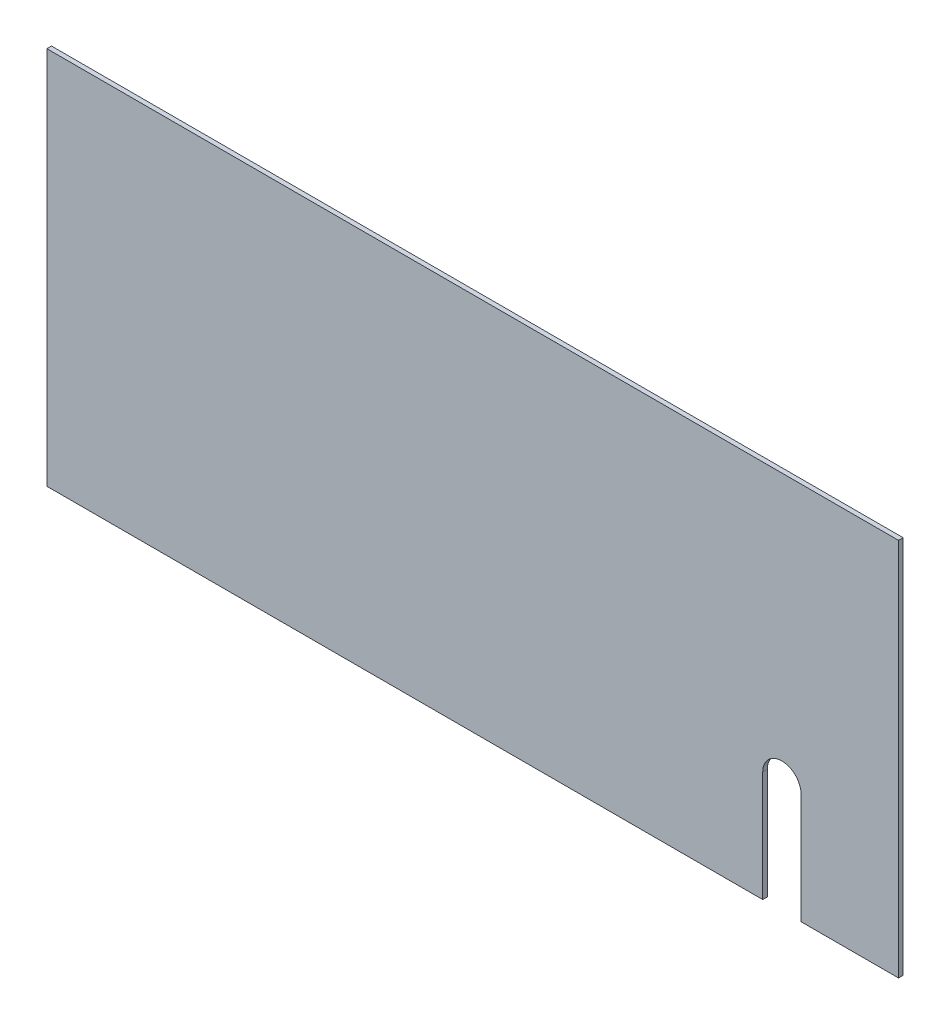
from build123d import *

# Parameters (mm, degrees)
ESQUISSE1_W             = 555
ESQUISSE1_H             = 247
BOSS_EXTRU_1_DEPTH      = 3
ENL_V_MAT_EXTRU_2_DEPTH = 72


with BuildPart() as part:
    # Esquisse1 → Boss.-Extru.1 (new body)
    with BuildSketch(Plane.XY):
        with Locations((-10.243311569, 121.33382636)):
            Rectangle(ESQUISSE1_W, ESQUISSE1_H)
    extrude(amount=BOSS_EXTRU_1_DEPTH)

    # Esquisse3 → Enlèv. mat.-Extru.2 (cut)
    with BuildSketch(Plane.XY.offset(3)):
        with BuildLine():
            Line((178.756688431, 69.83382636), (178.756688431, -2.16617364))
            Line((178.756688431, -2.16617364), (203.756688431, -2.16617364))
            Line((203.756688431, -2.16617364), (203.756688431, 69.83382636))
            ThreePointArc((203.756688431, 69.83382636), (191.256688431, 82.33382636), (178.756688431, 69.83382636))
        make_face()
    extrude(amount=-ENL_V_MAT_EXTRU_2_DEPTH, mode=Mode.SUBTRACT)


solid = part.part
